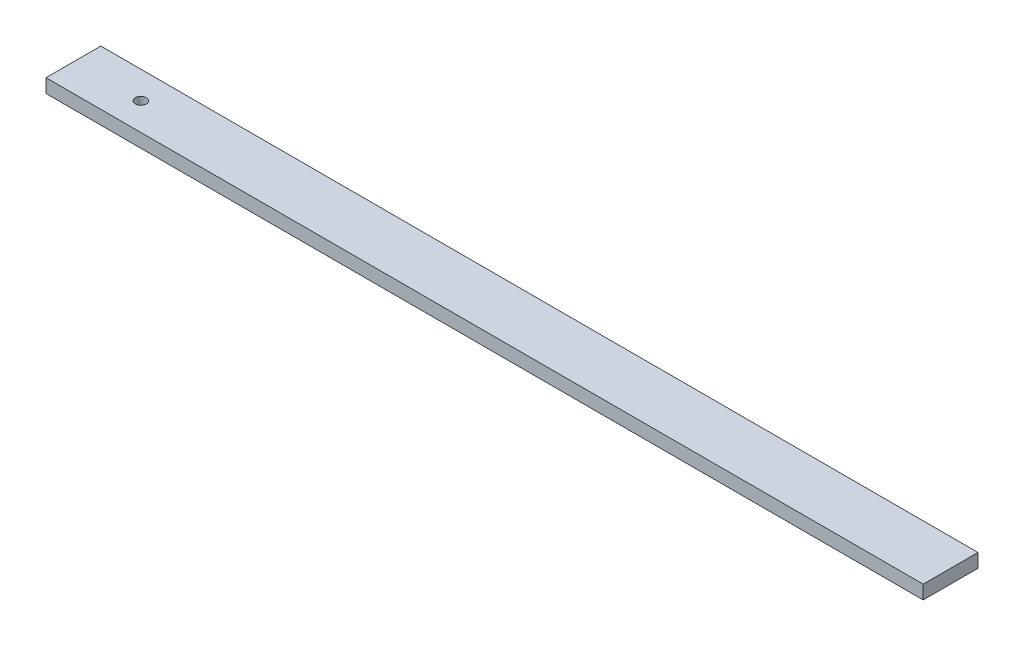
from build123d import *

# Parameters (mm, degrees)
SKETCH1_W           = 1
SKETCH1_H           = 0.25
BOSS_EXTRUDE1_DEPTH = 16
SCALE1_SCALE        = 25.4
SKETCH2_R           = 2.54
CUT_EXTRUDE1_DEPTH  = 7.35


with BuildPart() as part:
    # Sketch1 → Boss-Extrude1 (new body)
    with BuildSketch(Plane(origin=(0, 0, 0), x_dir=(0, 0, -1), z_dir=(1, 0, 0))):
        with Locations((0.5, 0.125)):
            Rectangle(SKETCH1_W, SKETCH1_H)
    extrude(amount=BOSS_EXTRUDE1_DEPTH)


with BuildPart() as part_1:
    # Scale1: scaled about (8, 0.125, -0.5)
    add(part.part.scale(SCALE1_SCALE).moved(Location((-195.2, -3.05, 12.2))))

    # Sketch2 → Cut-Extrude1 (cut, through all)
    with BuildSketch(Plane(origin=(0, 3.3, 0), x_dir=(1, 0, 0), z_dir=(0, 1, 0))):
        with Locations((-163.958, 0.5)):
            Circle(SKETCH2_R)
    extrude(amount=-CUT_EXTRUDE1_DEPTH, mode=Mode.SUBTRACT)


solid = part_1.part
